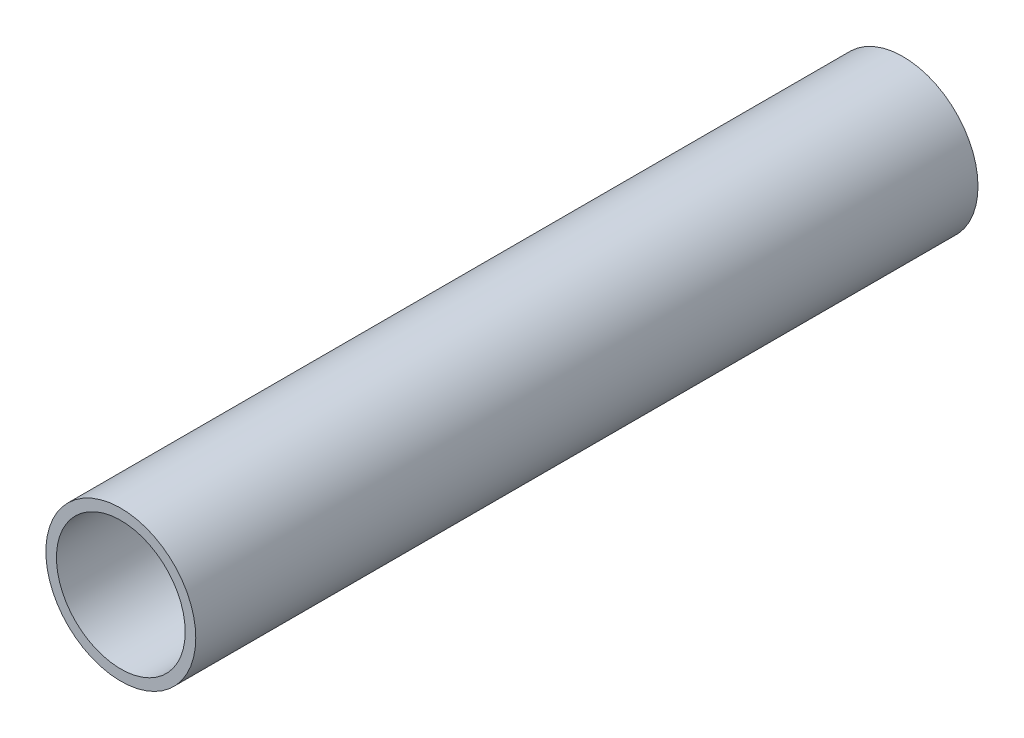
from build123d import *

# Parameters (mm, degrees)
SKETCH1_R           = 36.5125
SKETCH1_R_2         = 31.3563
BOSS_EXTRUDE1_DEPTH = 381


with BuildPart() as part:
    # Sketch1 → Boss-Extrude1 (new body)
    with BuildSketch(Plane.XY):
        Circle(SKETCH1_R)
        Circle(SKETCH1_R_2, mode=Mode.SUBTRACT)
    extrude(amount=BOSS_EXTRUDE1_DEPTH)


solid = part.part
